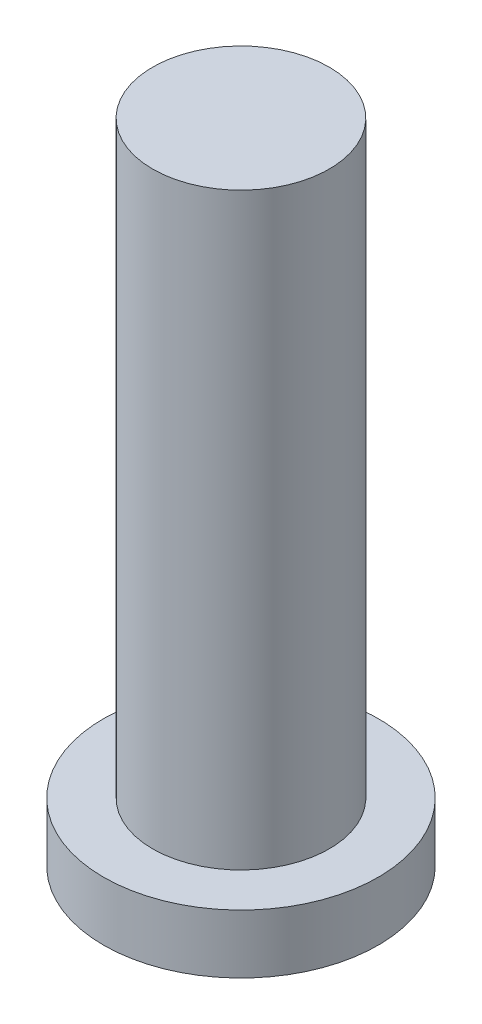
from build123d import *

# Parameters (mm, degrees)
SKETCH1_R           = 9
BOSS_EXTRUDE2_DEPTH = 60
SKETCH1_3_R         = 14
BOSS_EXTRUDE3_DEPTH = 6


with BuildPart() as part:
    # Sketch1 → Boss-Extrude2 (new body)
    with BuildSketch(Plane(origin=(0, 0, 0), x_dir=(1, 0, 0), z_dir=(0, 1, 0))):
        Circle(SKETCH1_R)
    extrude(amount=BOSS_EXTRUDE2_DEPTH)

    # Sketch1_3 → Boss-Extrude3 (add)
    with BuildSketch(Plane(origin=(0, 0, 0), x_dir=(1, 0, 0), z_dir=(0, 1, 0))):
        Circle(SKETCH1_3_R)
    extrude(amount=-BOSS_EXTRUDE3_DEPTH)


solid = part.part
